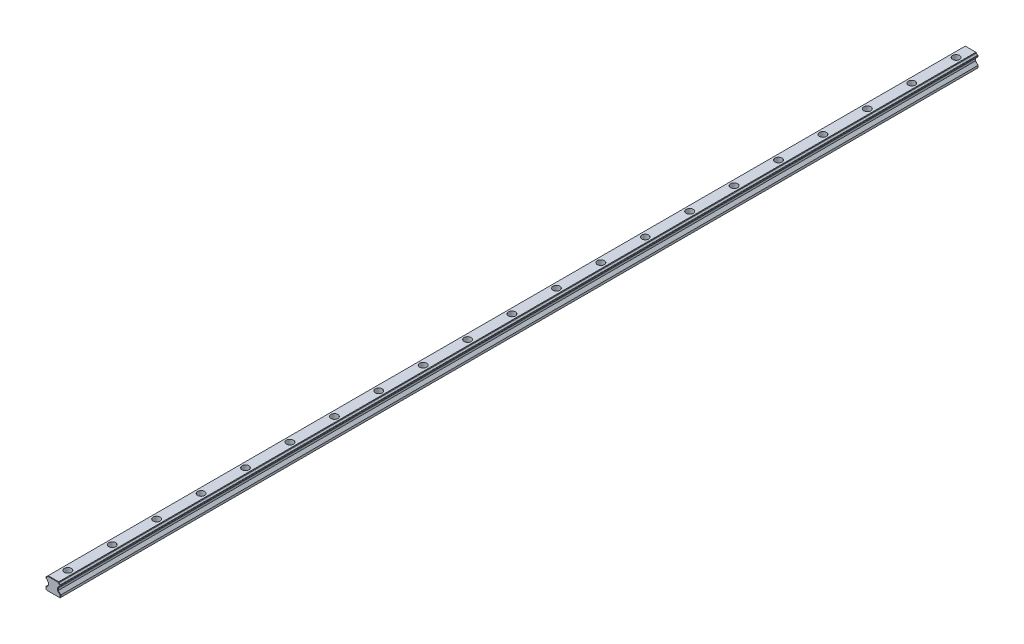
from build123d import *

# Parameters (mm, degrees)
BOSS_EXTRUDE1_DEPTH      = 620
BOSS_EXTRUDE1_DEPTH_BACK = 620
LPATTERN2_COUNT          = 21
LPATTERN2_PITCH          = 60
CHAMFER1_SIZE            = 0.5


with BuildPart() as part:
    # Sketch3 → Boss-Extrude1 (new body, two sides)
    with BuildSketch(Plane.XY) as boss_extrude1_sk:
        with BuildLine():
            Line((3, 9), (-3, 9))
            Line((-3, 9), (-7.160036564, 9))
            Line((-7.160036564, 9), (-7.767930373, 8.392105714))
            ThreePointArc((-7.767930373, 8.392105714), (-8.344874488, 7.264307267), (-9.472673258, 6.687363783))
            Line((-9.472673258, 6.687363783), (-10, 6.160037041))
            Line((-10, 6.160037041), (-10, 4.82918644))
            Line((-10, 4.82918644), (-9.472673258, 4.314376637))
            ThreePointArc((-9.472673258, 4.314376637), (-8.341068744, 3.731631743), (-7.767930373, 2.595131504))
            Line((-7.767930373, 2.595131504), (-6.550048828, 1.379235268))
            Line((-6.550048828, 1.379235268), (-6.550048828, -1.550048828))
            Line((-6.550048828, -1.550048828), (-10, -4.999922752))
            Line((-10, -4.999922752), (-10, -8))
            Line((-10, -8), (-9, -9))
            Line((-9, -9), (0, -9))
            Line((0, -9), (9, -9))
            Line((9, -9), (10, -8))
            Line((10, -8), (10, -4.999922752))
            Line((10, -4.999922752), (6.550048828, -1.550048828))
            Line((6.550048828, -1.550048828), (6.550048828, 1.379235268))
            Line((6.550048828, 1.379235268), (7.767930373, 2.595131504))
            ThreePointArc((7.767930373, 2.595131504), (8.341068744, 3.731631743), (9.472673258, 4.314376637))
            Line((9.472673258, 4.314376637), (10, 4.82918644))
            Line((10, 4.82918644), (10, 6.160037041))
            Line((10, 6.160037041), (9.472673258, 6.687363783))
            ThreePointArc((9.472673258, 6.687363783), (8.344874488, 7.264307267), (7.767930373, 8.392105714))
            Line((7.767930373, 8.392105714), (7.160036564, 9))
            Line((7.160036564, 9), (3, 9))
        make_face()
    extrude(amount=BOSS_EXTRUDE1_DEPTH)
    extrude(boss_extrude1_sk.sketch, amount=-BOSS_EXTRUDE1_DEPTH_BACK)

    # Sketch4 → Cut-Revolve1 (revolve, cut)
    with BuildSketch(Plane(origin=(0, 0, 0), x_dir=(0, 0, -1), z_dir=(1, 0, 0))):
        Polygon((-595.25, 9), (-600, 9), (-600, -9), (-597, -9), (-597, 0.5), (-595.25, 0.5), align=None)
    cut_revolve1 = revolve(axis=Axis((0, 9, 600), (0, -1, 0)), mode=Mode.SUBTRACT)

    # LPattern2: Cut-Revolve1 ×21
    with Locations(*[(0, 0, -i * LPATTERN2_PITCH) for i in range(1, LPATTERN2_COUNT)]):
        add(cut_revolve1, mode=Mode.SUBTRACT)

    # Chamfer1
    chamfer1_edges = [part.edges().sort_by_distance(p)[0] for p in [
        (-6.550048828, -0.08540678, 620),
        (-8.275024414, -3.27498579, 620),
        (-10, -6.499961376, 620),
        (-9.5, -8.5, 620),
        (0, -9, 620),
        (9.5, -8.5, 620),
        (10, -6.499961376, 620),
        (8.275024414, -3.27498579, 620),
        (6.550048828, -0.08540678, 620),
        (-8.341068744, 3.731631743, 620),
        (7.158989601, 1.987183386, 620),
        (8.341068744, 3.731631743, 620),
        (9.736336629, 4.571781538, 620),
        (-9.736336629, 4.571781538, -620),
        (-10, 5.49461174, -620),
        (10, 5.49461174, 620),
        (-9.736336629, 6.423700412, -620),
        (-7.463983469, 8.696052857, -620),
        (0, 9, -620),
        (7.463983469, 8.696052857, -620),
        (9.736336629, 6.423700412, -620),
        (10, 5.49461174, -620),
        (9.736336629, 6.423700412, 620),
        (9.736336629, 4.571781538, -620),
        (7.158989601, 1.987183386, -620),
        (6.550048828, -0.08540678, -620),
        (8.275024414, -3.27498579, -620),
        (10, -6.499961376, -620),
        (9.5, -8.5, -620),
        (0, -9, -620),
        (8.344874488, 7.264307267, 620),
        (-9.5, -8.5, -620),
        (-10, -6.499961376, -620),
        (-8.275024414, -3.27498579, -620),
        (-6.550048828, -0.08540678, -620),
        (-7.158989601, 1.987183386, -620),
        (-8.341068744, 3.731631743, -620),
        (-8.344874488, 7.264307267, -620),
        (8.344874488, 7.264307267, -620),
        (8.341068744, 3.731631743, -620),
        (7.463983469, 8.696052857, 620),
        (0, 9, 620),
        (-7.463983469, 8.696052857, 620),
        (-8.344874488, 7.264307267, 620),
        (-7.158989601, 1.987183386, 620),
        (-9.736336629, 6.423700412, 620),
        (-10, 5.49461174, 620),
        (-9.736336629, 4.571781538, 620),
    ]]
    chamfer(chamfer1_edges, length=CHAMFER1_SIZE)


solid = part.part
